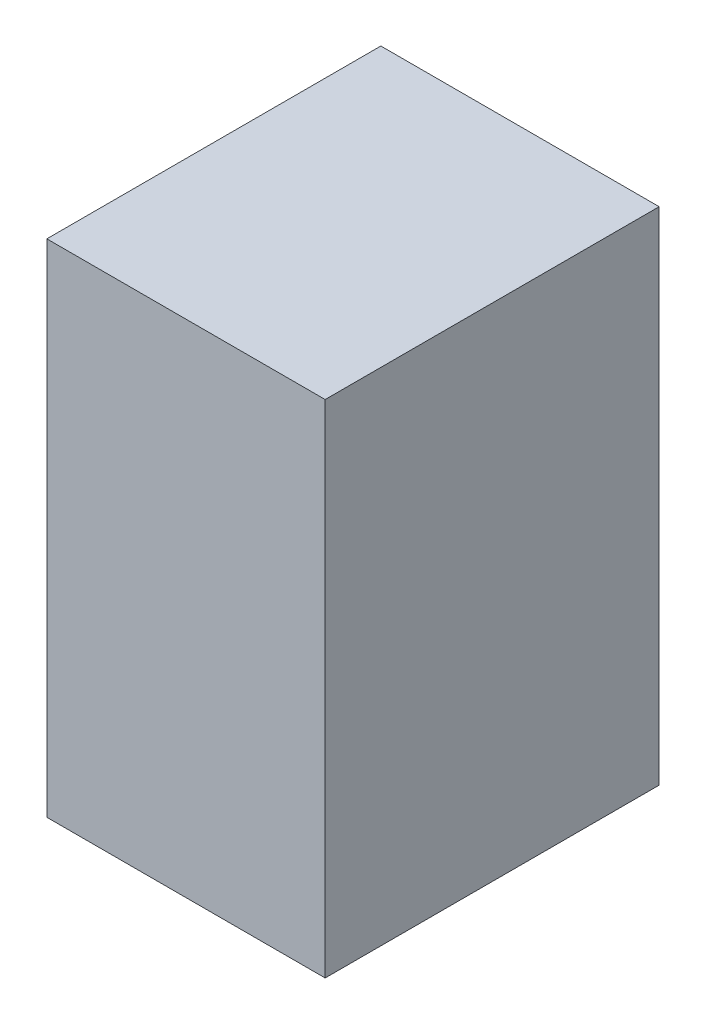
from build123d import *

# Parameters (mm, degrees)
SKETCH2_W           = 45
SKETCH2_H           = 30
BOSS_EXTRUDE1_DEPTH = 25


with BuildPart() as part:
    # Sketch2 → Boss-Extrude1 (new body)
    with BuildSketch(Plane.YZ):
        Rectangle(SKETCH2_W, SKETCH2_H)
    extrude(amount=BOSS_EXTRUDE1_DEPTH)


solid = part.part
